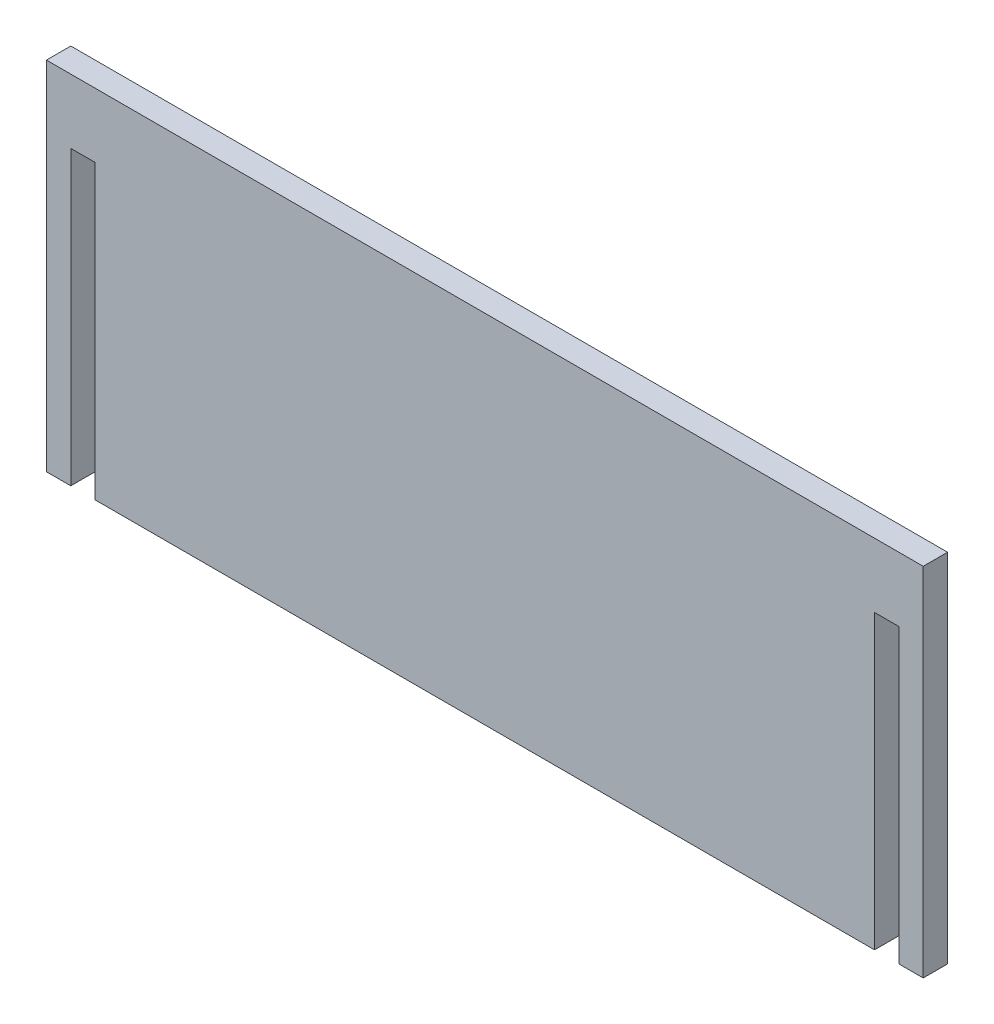
from build123d import *

# Parameters (mm, degrees)
SKETCH1_W           = 114.3
SKETCH1_H           = 46.482
BOSS_EXTRUDE1_DEPTH = 3.175
SKETCH2_W           = 3.175
SKETCH2_H           = 38.1
CUT_EXTRUDE1_DEPTH  = 4.175


with BuildPart() as part:
    # Sketch1 → Boss-Extrude1 (new body)
    with BuildSketch(Plane.XY):
        with Locations((57.15, 23.241)):
            Rectangle(SKETCH1_W, SKETCH1_H)
    extrude(amount=BOSS_EXTRUDE1_DEPTH)

    # Sketch2 → Cut-Extrude1 (cut, through all)
    with BuildSketch(Plane.XY.offset(3.175)):
        with Locations((4.7625, 19.05)):
            Rectangle(SKETCH2_W, SKETCH2_H)
        with Locations((109.5375, 19.05)):
            Rectangle(SKETCH2_W, SKETCH2_H)
    extrude(amount=-CUT_EXTRUDE1_DEPTH, mode=Mode.SUBTRACT)


solid = part.part
